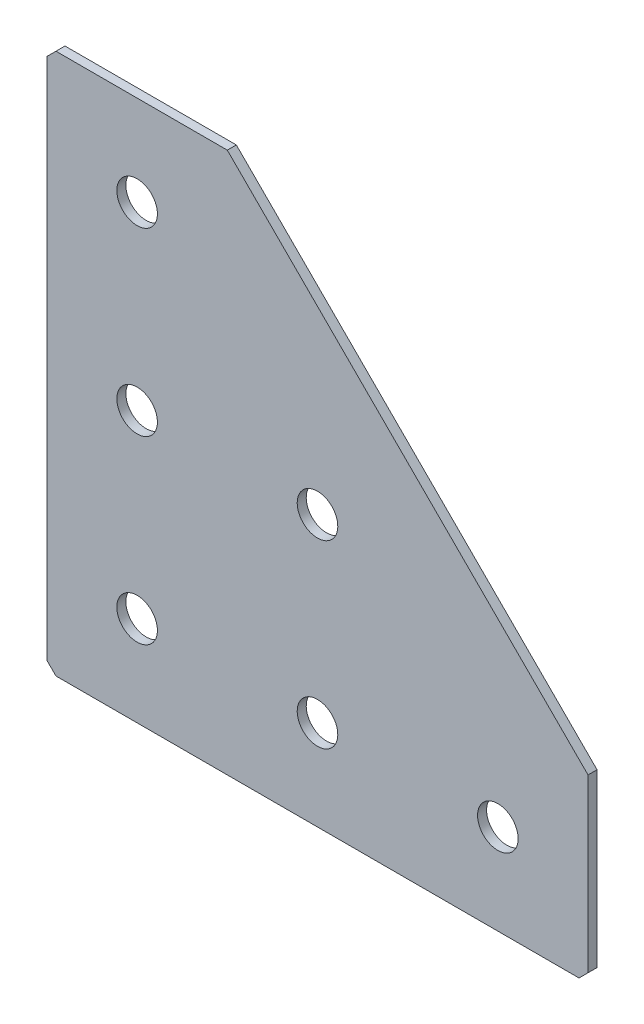
from build123d import *

# Parameters (mm, degrees)
EXTRUDE_1_DEPTH   = 2
HOLE_WIZARD_M81_D = 9
CHAMFER_1_SIZE    = 2


with BuildPart() as part:
    # Эскиз1 → Бобышка-Вытянуть1 (new body)
    with BuildSketch(Plane(origin=(0, 0, 0), x_dir=(1, 0, 0), z_dir=(0, 0, -1))):
        Polygon((0, 0), (0, 120), (120, 120), (120, 80), (40, 0), align=None)
    extrude(amount=EXTRUDE_1_DEPTH)

    # Отверстие с зазором M81 (through all)
    with Locations(Plane(origin=(0, 0, -2), x_dir=(1, 0, 0), z_dir=(0, 0, -1))):
        with Locations((60, 100), (20, 100), (20, 60), (20, 20), (100, 100), (60, 60)):
            Hole(HOLE_WIZARD_M81_D / 2)

    # Фаска1
    chamfer_1_edges = [part.edges().sort_by_distance(p)[0] for p in [
        (0, 0, -1),
        (0, -120, -1),
        (120, -120, -1),
    ]]
    chamfer(chamfer_1_edges, length=CHAMFER_1_SIZE)


solid = part.part
